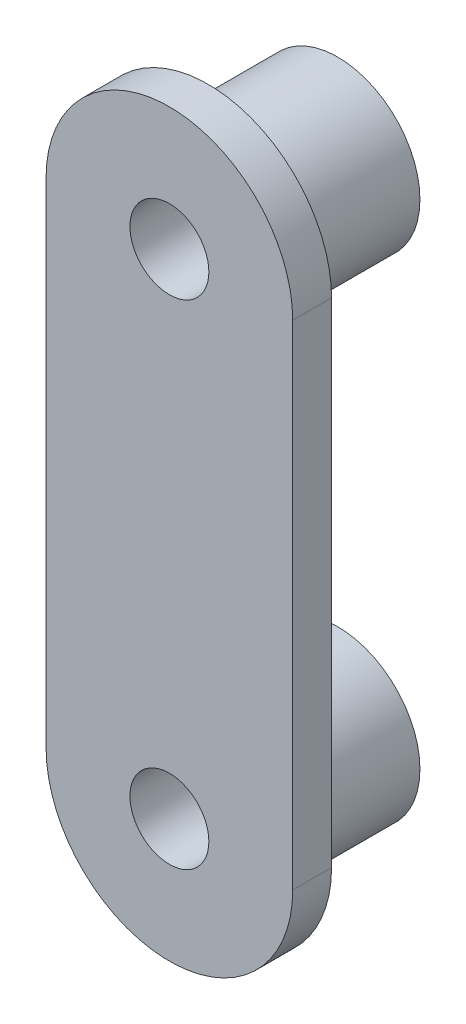
from build123d import *

# Parameters (mm, degrees)
SKETCH1_R           = 1.524
BOSS_EXTRUDE1_DEPTH = 1.5
BOSS_EXTRUDE2_START = -5
SKETCH1_7_R         = 3.175
SKETCH1_7_R_2       = 1.524
BOSS_EXTRUDE2_DEPTH = 5


with BuildPart() as part:
    # Sketch1 → Boss-Extrude1 (new body)
    with BuildSketch(Plane.XY):
        with BuildLine():
            Line((9.525, -19.05), (9.525, 0))
            ThreePointArc((9.525, 0), (4.7625, 4.7625), (0, 0))
            Line((0, 0), (0, -19.05))
            ThreePointArc((0, -19.05), (4.7625, -23.8125), (9.525, -19.05))
        make_face()
        with Locations((4.7625, -19.05)):
            Circle(SKETCH1_R, mode=Mode.SUBTRACT)
        with Locations((4.7625, 0)):
            Circle(SKETCH1_R, mode=Mode.SUBTRACT)
    extrude(amount=BOSS_EXTRUDE1_DEPTH)

    # Sketch1_7 → Boss-Extrude2 (add)
    # profile 1 of 2: a face of its own
    with BuildSketch(Plane.XY.offset(BOSS_EXTRUDE2_START)):
        with Locations((4.7625, 0)):
            Circle(SKETCH1_7_R)
        with Locations((4.7625, 0)):
            Circle(SKETCH1_7_R_2, mode=Mode.SUBTRACT)
    # profile 2 of 2: a face of its own
    with BuildSketch(Plane.XY.offset(BOSS_EXTRUDE2_START)):
        with Locations((4.7625, -19.05)):
            Circle(SKETCH1_7_R)
        with Locations((4.7625, -19.05)):
            Circle(SKETCH1_7_R_2, mode=Mode.SUBTRACT)
    extrude(amount=BOSS_EXTRUDE2_DEPTH)


solid = part.part
